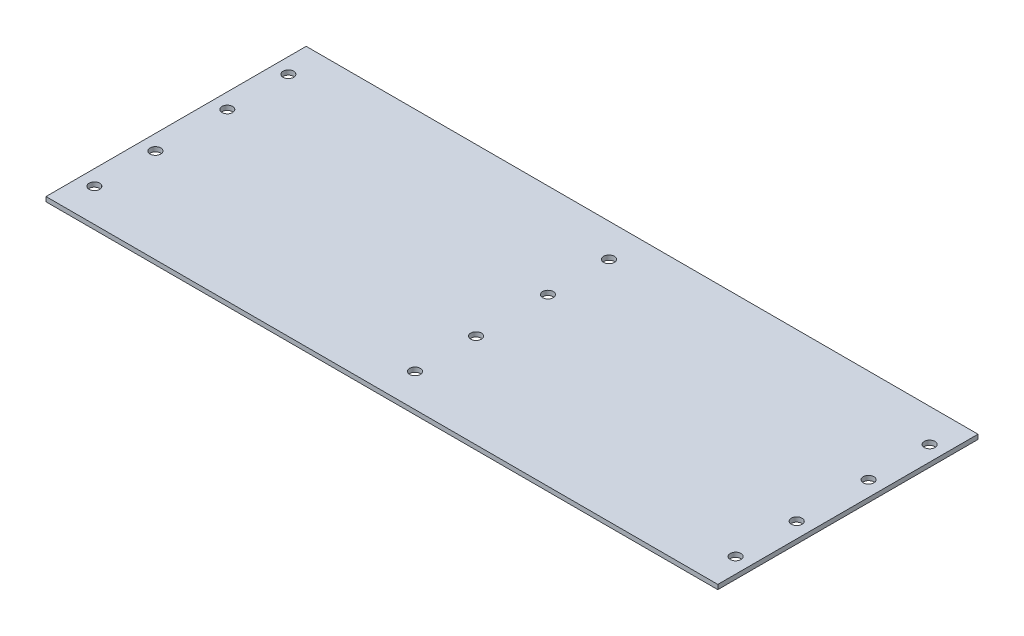
from build123d import *

# Parameters (mm, degrees)
SKETCH_1_W          = 220
SKETCH_1_H          = 85.2
EXTRUDE_1_DEPTH     = 1.5
SKETCH_2_R          = 1.75
CUT_EXTRUDE_1_DEPTH = 10


with BuildPart() as part:
    # 草图1 → 凸台-拉伸1 (new body)
    with BuildSketch(Plane(origin=(0, 0, 0), x_dir=(1, 0, 0), z_dir=(0, 1, 0))):
        with Locations((44.295012832, 1.717252595)):
            Rectangle(SKETCH_1_W, SKETCH_1_H)
    extrude(amount=EXTRUDE_1_DEPTH)

    # 草图2 → 切除-拉伸1 (cut)
    with BuildSketch(Plane(origin=(0, 1.5, 0), x_dir=(1, 0, 0), z_dir=(0, 1, 0))):
        with Locations((149.295012832, -30.052747405)):
            Circle(SKETCH_2_R)
        with Locations((149.295012832, -10.052747405)):
            Circle(SKETCH_2_R)
        with Locations((44.295012832, -10.052747405)):
            Circle(SKETCH_2_R)
        with Locations((44.295012832, -30.052747405)):
            Circle(SKETCH_2_R)
        with Locations((44.295012832, 13.487252595)):
            Circle(SKETCH_2_R)
        with Locations((44.295012832, 33.487252595)):
            Circle(SKETCH_2_R)
        with Locations((149.295012832, 13.487252595)):
            Circle(SKETCH_2_R)
        with Locations((149.295012832, 33.487252595)):
            Circle(SKETCH_2_R)
        with Locations((-60.704987168, 33.487252595)):
            Circle(SKETCH_2_R)
        with Locations((-60.704987168, 13.487252595)):
            Circle(SKETCH_2_R)
        with Locations((-60.704987168, -10.052747405)):
            Circle(SKETCH_2_R)
        with Locations((-60.704987168, -30.052747405)):
            Circle(SKETCH_2_R)
    extrude(amount=-CUT_EXTRUDE_1_DEPTH, mode=Mode.SUBTRACT)


solid = part.part
